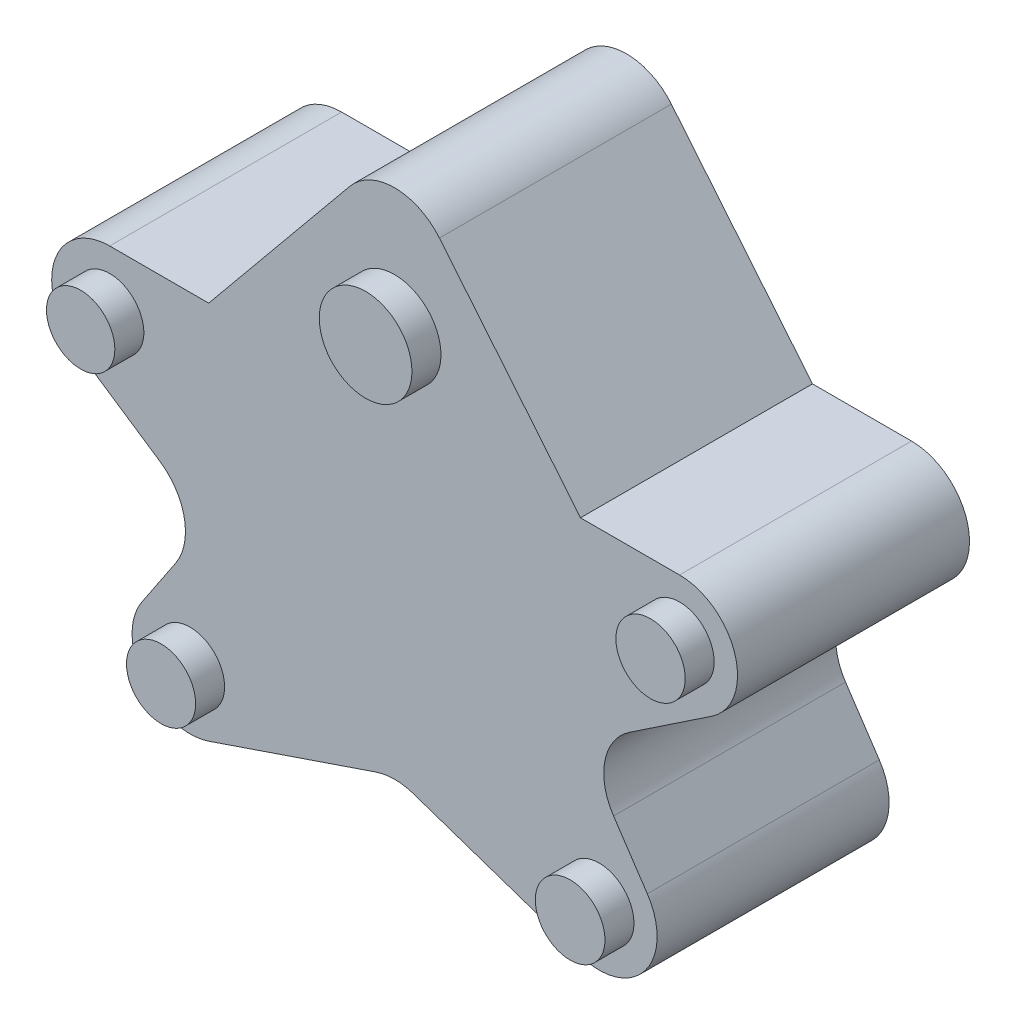
from build123d import *

# Parameters (mm, degrees)
BOSS_EXTRUDE1_DEPTH = 40
FILLET1_R           = 10
SKETCH3_R           = 7.989564155
SKETCH3_R_2         = 5.892903955
SKETCH3_R_3         = 5.960312231
SKETCH3_R_4         = 6.003710983
SKETCH3_R_5         = 5.972502613
BOSS_EXTRUDE2_DEPTH = 5


with BuildPart() as part:
    # Sketch2 → Boss-Extrude1 (new body)
    with BuildSketch(Plane.XY):
        Polygon((10.161880784, 60.526315789), (60.161880784, 60.526315789), (92.220072964, 99.539400074), (124.278265144, 60.526315789), (174.278265144, 60.526315789), (124.413003502, 27.157832435), (152.220072964, -14.396552267), (92.220072964, 6.015037594), (32.220072964, -14.396552267), (60.027142426, 27.157832435), align=None)
    extrude(amount=BOSS_EXTRUDE1_DEPTH)

    # Fillet1
    fillet1_edges = [part.edges().sort_by_distance(p)[0] for p in [
        (10.161880784, 60.526315789, 20),
        (92.220072964, 99.539400074, 20),
        (174.278265144, 60.526315789, 20),
        (124.413003502, 27.157832435, 20),
        (152.220072964, -14.396552267, 20),
        (92.220072964, 6.015037594, 20),
        (32.220072964, -14.396552267, 20),
        (60.027142426, 27.157832435, 20),
    ]]
    fillet(fillet1_edges, radius=FILLET1_R)

    # Sketch3 → Boss-Extrude2 (add)
    with BuildSketch(Plane.XY.offset(40)):
        with Locations((92.220072964, 72.831646457)):
            Circle(SKETCH3_R)
        with Locations((43.086739991, 50.526315789)):
            Circle(SKETCH3_R_2)
        with Locations((56.950737692, 4.579469525)):
            Circle(SKETCH3_R_3)
        with Locations((127.489408235, 4.579469525)):
            Circle(SKETCH3_R_4)
        with Locations((141.353405936, 50.526315789)):
            Circle(SKETCH3_R_5)
    extrude(amount=BOSS_EXTRUDE2_DEPTH)


solid = part.part
